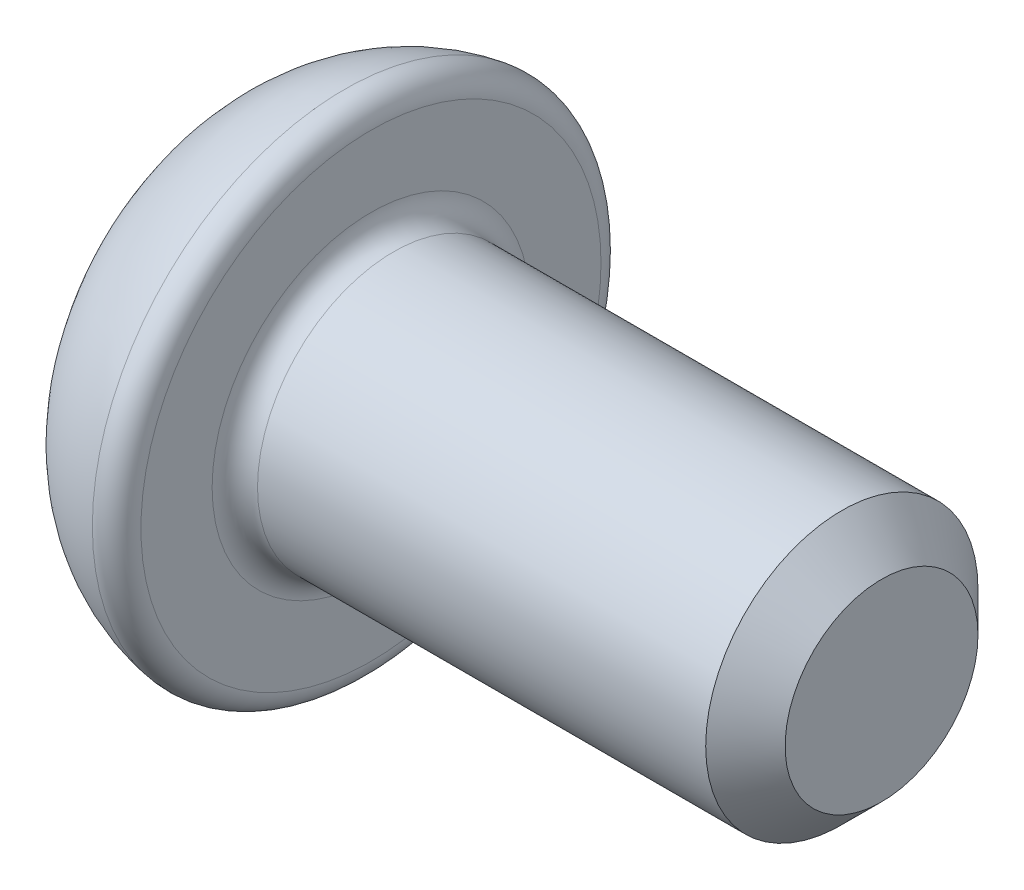
from build123d import *

# Parameters (mm, degrees)
CUT_EXTRUDE1_DEPTH = 0.9


with BuildPart() as part:
    # Sketch1 → Revolve1 (revolve)
    with BuildSketch(Plane.XY):
        with BuildLine():
            Line((0, 0), (0, 0.742857779))
            ThreePointArc((0, 0.742857779), (0.360668212, 1.718523233), (1.269230769, 2.225))
            ThreePointArc((1.269230769, 2.225), (1.430088727, 2.179291942), (1.5, 2.027381037))
            Line((1.5, 2.027381037), (1.5, 1.4))
            ThreePointArc((1.5, 1.4), (1.558578644, 1.258578644), (1.7, 1.2))
            Line((1.7, 1.2), (5.65, 1.2))
            Line((5.65, 1.2), (6, 0.85))
            Line((6, 0.85), (6, 0))
            Line((6, 0), (0, 0))
        make_face()
    revolve(axis=Axis((0, 0, 0), (-1, 0, 0)))

    # Sketch2 → Cut-Extrude1 (cut)
    with BuildSketch(Plane.ZY):
        Polygon((0.75, -0.433012702), (0.75, 0.433012702), (0, 0.866025404), (-0.75, 0.433012702), (-0.75, -0.433012702), (0, -0.866025404), align=None)
    extrude(amount=-CUT_EXTRUDE1_DEPTH, mode=Mode.SUBTRACT)


solid = part.part
